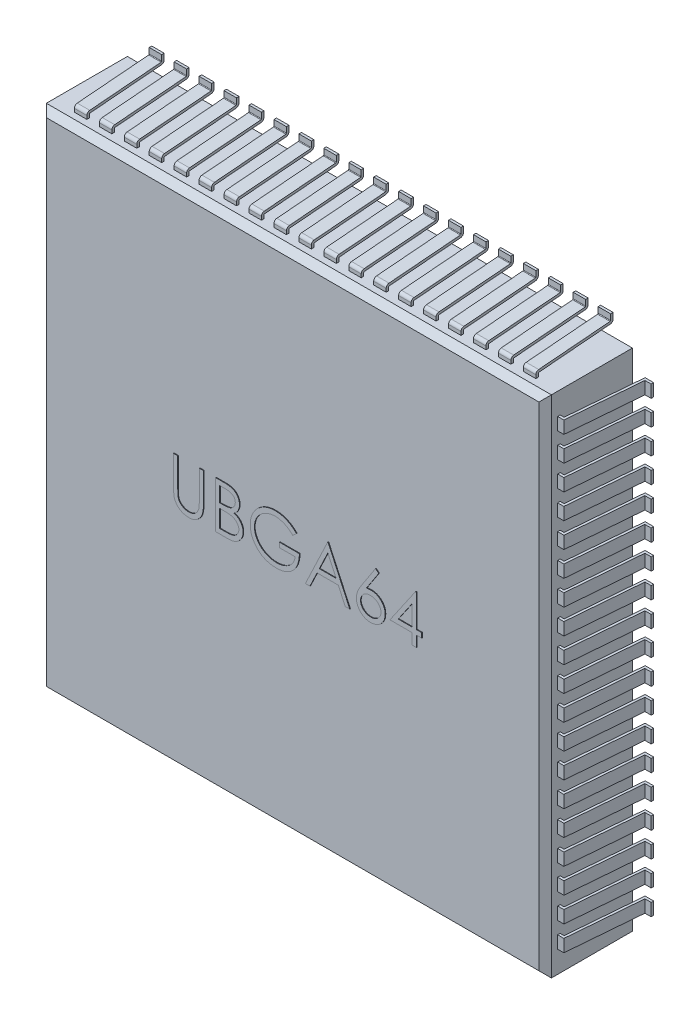
from build123d import *

# Parameters (mm, degrees)
COMPONENT_OUTLINE_W   = 8.1
COMPONENT_OUTLINE_H   = 8.1
EXTRUDE1_DEPTH        = 1.4
EXTRUDE_THIN1_DEPTH   = 0.1
LPATTERN1_COUNT       = 10
LPATTERN1_PITCH       = 0.4
LPATTERN1_COL_COUNT   = 10
LPATTERN1_COL_PITCH   = 0.4
MIRROR1_COPY_1_DEPTH  = 0.1
MIRROR1_COPY_2_DEPTH  = 0.1
MIRROR1_COPY_3_DEPTH  = 0.1
MIRROR1_COPY_4_DEPTH  = 0.1
MIRROR1_COPY_5_DEPTH  = 0.1
MIRROR1_COPY_6_DEPTH  = 0.1
MIRROR1_COPY_7_DEPTH  = 0.1
MIRROR1_COPY_8_DEPTH  = 0.1
MIRROR1_COPY_9_DEPTH  = 0.1
MIRROR1_COPY_10_DEPTH = 0.1
MIRROR1_COPY_11_DEPTH = 0.1
MIRROR1_COPY_12_DEPTH = 0.1
MIRROR1_COPY_13_DEPTH = 0.1
MIRROR1_COPY_14_DEPTH = 0.1
MIRROR1_COPY_15_DEPTH = 0.1
MIRROR1_COPY_16_DEPTH = 0.1
MIRROR1_COPY_17_DEPTH = 0.1
MIRROR1_COPY_18_DEPTH = 0.1
EXTRUDE_THIN2_DEPTH   = 0.1
LPATTERN2_COUNT       = 10
LPATTERN2_PITCH       = 0.4
LPATTERN2_COL_COUNT   = 10
LPATTERN2_COL_PITCH   = 0.4
MIRROR2_COPY_1_DEPTH  = 0.1
MIRROR2_COPY_2_DEPTH  = 0.1
MIRROR2_COPY_3_DEPTH  = 0.1
MIRROR2_COPY_4_DEPTH  = 0.1
MIRROR2_COPY_5_DEPTH  = 0.1
MIRROR2_COPY_6_DEPTH  = 0.1
MIRROR2_COPY_7_DEPTH  = 0.1
MIRROR2_COPY_8_DEPTH  = 0.1
MIRROR2_COPY_9_DEPTH  = 0.1
MIRROR2_COPY_10_DEPTH = 0.1
MIRROR2_COPY_11_DEPTH = 0.1
MIRROR2_COPY_12_DEPTH = 0.1
MIRROR2_COPY_13_DEPTH = 0.1
MIRROR2_COPY_14_DEPTH = 0.1
MIRROR2_COPY_15_DEPTH = 0.1
MIRROR2_COPY_16_DEPTH = 0.1
MIRROR2_COPY_17_DEPTH = 0.1
MIRROR2_COPY_18_DEPTH = 0.1
CHAMFER1_SIZE         = 0.1
EXTRUDE2_DEPTH        = 0.01


with BuildPart() as part:
    # COMPONENT_OUTLINE → Extrude1 (new body)
    with BuildSketch(Plane.XY):
        Rectangle(COMPONENT_OUTLINE_W, COMPONENT_OUTLINE_H)
    extrude(amount=EXTRUDE1_DEPTH)

    # Sketch1 → Extrude-Thin1 (add, symmetric)
    with BuildSketch(Plane(origin=(0, 0, 0), x_dir=(0, 0, -1), z_dir=(1, 0, 0))):
        with BuildLine():
            Line((-1.2, 4.05), (-1.2, 4.103993356))
            ThreePointArc((-1.2, 4.103993356), (-1.186794114, 4.13784883), (-1.154152274, 4.153820644))
            Line((-1.154152274, 4.153820644), (-0.009169545, 4.249235871))
            ThreePointArc((-0.009169545, 4.249235871), (-0.002641177, 4.252430234), (0, 4.259201329))
            Line((0, 4.259201329), (0, 4.35))
            Line((0, 4.35), (0.04, 4.35))
            Line((0.04, 4.35), (0.04, 4.259201329))
            ThreePointArc((0.04, 4.259201329), (0.026794114, 4.225345854), (-0.005847726, 4.209374041))
            Line((-0.005847726, 4.209374041), (-1.150830455, 4.113958814))
            ThreePointArc((-1.150830455, 4.113958814), (-1.157358823, 4.110764451), (-1.16, 4.103993356))
            Line((-1.16, 4.103993356), (-1.16, 4.05))
            Line((-1.16, 4.05), (-1.2, 4.05))
        make_face()
    extrude_thin1 = extrude(amount=EXTRUDE_THIN1_DEPTH, both=True)

    # LPattern1: Extrude-Thin1 ×10
    with Locations(*[(-i * LPATTERN1_PITCH, 0, 0) for i in range(1, LPATTERN1_COUNT)]):
        add(extrude_thin1)

    # LPattern1 col: Extrude-Thin1 ×10
    with Locations(*[(i * LPATTERN1_COL_PITCH, 0, 0) for i in range(1, LPATTERN1_COL_COUNT)]):
        add(extrude_thin1)

    # Mirror1: Extrude-Thin1 across plane
    add(extrude_thin1.mirror(Plane.ZX))

    # Mirror1 copy 1 sketch → Mirror1 copy 1 (add, symmetric)
    with BuildSketch(Plane(origin=(-0.4, 0, 0), x_dir=(0, 0, -1), z_dir=(1, 0, 0))):
        with BuildLine():
            Line((-1.2, -4.05), (-1.2, -4.103993356))
            ThreePointArc((-1.2, -4.103993356), (-1.186794114, -4.13784883), (-1.154152274, -4.153820644))
            Line((-1.154152274, -4.153820644), (-0.009169545, -4.249235871))
            ThreePointArc((-0.009169545, -4.249235871), (-0.002641177, -4.252430234), (0, -4.259201329))
            Line((0, -4.259201329), (0, -4.35))
            Line((0, -4.35), (0.04, -4.35))
            Line((0.04, -4.35), (0.04, -4.259201329))
            ThreePointArc((0.04, -4.259201329), (0.026794114, -4.225345854), (-0.005847726, -4.209374041))
            Line((-0.005847726, -4.209374041), (-1.150830455, -4.113958814))
            ThreePointArc((-1.150830455, -4.113958814), (-1.157358823, -4.110764451), (-1.16, -4.103993356))
            Line((-1.16, -4.103993356), (-1.16, -4.05))
            Line((-1.16, -4.05), (-1.2, -4.05))
        make_face()
    extrude(amount=MIRROR1_COPY_1_DEPTH, both=True)

    # Mirror1 copy 2 sketch → Mirror1 copy 2 (add, symmetric)
    with BuildSketch(Plane(origin=(-0.8, 0, 0), x_dir=(0, 0, -1), z_dir=(1, 0, 0))):
        with BuildLine():
            Line((-1.2, -4.05), (-1.2, -4.103993356))
            ThreePointArc((-1.2, -4.103993356), (-1.186794114, -4.13784883), (-1.154152274, -4.153820644))
            Line((-1.154152274, -4.153820644), (-0.009169545, -4.249235871))
            ThreePointArc((-0.009169545, -4.249235871), (-0.002641177, -4.252430234), (0, -4.259201329))
            Line((0, -4.259201329), (0, -4.35))
            Line((0, -4.35), (0.04, -4.35))
            Line((0.04, -4.35), (0.04, -4.259201329))
            ThreePointArc((0.04, -4.259201329), (0.026794114, -4.225345854), (-0.005847726, -4.209374041))
            Line((-0.005847726, -4.209374041), (-1.150830455, -4.113958814))
            ThreePointArc((-1.150830455, -4.113958814), (-1.157358823, -4.110764451), (-1.16, -4.103993356))
            Line((-1.16, -4.103993356), (-1.16, -4.05))
            Line((-1.16, -4.05), (-1.2, -4.05))
        make_face()
    extrude(amount=MIRROR1_COPY_2_DEPTH, both=True)

    # Mirror1 copy 3 sketch → Mirror1 copy 3 (add, symmetric)
    with BuildSketch(Plane(origin=(-1.2, 0, 0), x_dir=(0, 0, -1), z_dir=(1, 0, 0))):
        with BuildLine():
            Line((-1.2, -4.05), (-1.2, -4.103993356))
            ThreePointArc((-1.2, -4.103993356), (-1.186794114, -4.13784883), (-1.154152274, -4.153820644))
            Line((-1.154152274, -4.153820644), (-0.009169545, -4.249235871))
            ThreePointArc((-0.009169545, -4.249235871), (-0.002641177, -4.252430234), (0, -4.259201329))
            Line((0, -4.259201329), (0, -4.35))
            Line((0, -4.35), (0.04, -4.35))
            Line((0.04, -4.35), (0.04, -4.259201329))
            ThreePointArc((0.04, -4.259201329), (0.026794114, -4.225345854), (-0.005847726, -4.209374041))
            Line((-0.005847726, -4.209374041), (-1.150830455, -4.113958814))
            ThreePointArc((-1.150830455, -4.113958814), (-1.157358823, -4.110764451), (-1.16, -4.103993356))
            Line((-1.16, -4.103993356), (-1.16, -4.05))
            Line((-1.16, -4.05), (-1.2, -4.05))
        make_face()
    extrude(amount=MIRROR1_COPY_3_DEPTH, both=True)

    # Mirror1 copy 4 sketch → Mirror1 copy 4 (add, symmetric)
    with BuildSketch(Plane(origin=(-1.6, 0, 0), x_dir=(0, 0, -1), z_dir=(1, 0, 0))):
        with BuildLine():
            Line((-1.2, -4.05), (-1.2, -4.103993356))
            ThreePointArc((-1.2, -4.103993356), (-1.186794114, -4.13784883), (-1.154152274, -4.153820644))
            Line((-1.154152274, -4.153820644), (-0.009169545, -4.249235871))
            ThreePointArc((-0.009169545, -4.249235871), (-0.002641177, -4.252430234), (0, -4.259201329))
            Line((0, -4.259201329), (0, -4.35))
            Line((0, -4.35), (0.04, -4.35))
            Line((0.04, -4.35), (0.04, -4.259201329))
            ThreePointArc((0.04, -4.259201329), (0.026794114, -4.225345854), (-0.005847726, -4.209374041))
            Line((-0.005847726, -4.209374041), (-1.150830455, -4.113958814))
            ThreePointArc((-1.150830455, -4.113958814), (-1.157358823, -4.110764451), (-1.16, -4.103993356))
            Line((-1.16, -4.103993356), (-1.16, -4.05))
            Line((-1.16, -4.05), (-1.2, -4.05))
        make_face()
    extrude(amount=MIRROR1_COPY_4_DEPTH, both=True)

    # Mirror1 copy 5 sketch → Mirror1 copy 5 (add, symmetric)
    with BuildSketch(Plane(origin=(-2, 0, 0), x_dir=(0, 0, -1), z_dir=(1, 0, 0))):
        with BuildLine():
            Line((-1.2, -4.05), (-1.2, -4.103993356))
            ThreePointArc((-1.2, -4.103993356), (-1.186794114, -4.13784883), (-1.154152274, -4.153820644))
            Line((-1.154152274, -4.153820644), (-0.009169545, -4.249235871))
            ThreePointArc((-0.009169545, -4.249235871), (-0.002641177, -4.252430234), (0, -4.259201329))
            Line((0, -4.259201329), (0, -4.35))
            Line((0, -4.35), (0.04, -4.35))
            Line((0.04, -4.35), (0.04, -4.259201329))
            ThreePointArc((0.04, -4.259201329), (0.026794114, -4.225345854), (-0.005847726, -4.209374041))
            Line((-0.005847726, -4.209374041), (-1.150830455, -4.113958814))
            ThreePointArc((-1.150830455, -4.113958814), (-1.157358823, -4.110764451), (-1.16, -4.103993356))
            Line((-1.16, -4.103993356), (-1.16, -4.05))
            Line((-1.16, -4.05), (-1.2, -4.05))
        make_face()
    extrude(amount=MIRROR1_COPY_5_DEPTH, both=True)

    # Mirror1 copy 6 sketch → Mirror1 copy 6 (add, symmetric)
    with BuildSketch(Plane(origin=(-2.4, 0, 0), x_dir=(0, 0, -1), z_dir=(1, 0, 0))):
        with BuildLine():
            Line((-1.2, -4.05), (-1.2, -4.103993356))
            ThreePointArc((-1.2, -4.103993356), (-1.186794114, -4.13784883), (-1.154152274, -4.153820644))
            Line((-1.154152274, -4.153820644), (-0.009169545, -4.249235871))
            ThreePointArc((-0.009169545, -4.249235871), (-0.002641177, -4.252430234), (0, -4.259201329))
            Line((0, -4.259201329), (0, -4.35))
            Line((0, -4.35), (0.04, -4.35))
            Line((0.04, -4.35), (0.04, -4.259201329))
            ThreePointArc((0.04, -4.259201329), (0.026794114, -4.225345854), (-0.005847726, -4.209374041))
            Line((-0.005847726, -4.209374041), (-1.150830455, -4.113958814))
            ThreePointArc((-1.150830455, -4.113958814), (-1.157358823, -4.110764451), (-1.16, -4.103993356))
            Line((-1.16, -4.103993356), (-1.16, -4.05))
            Line((-1.16, -4.05), (-1.2, -4.05))
        make_face()
    extrude(amount=MIRROR1_COPY_6_DEPTH, both=True)

    # Mirror1 copy 7 sketch → Mirror1 copy 7 (add, symmetric)
    with BuildSketch(Plane(origin=(-2.8, 0, 0), x_dir=(0, 0, -1), z_dir=(1, 0, 0))):
        with BuildLine():
            Line((-1.2, -4.05), (-1.2, -4.103993356))
            ThreePointArc((-1.2, -4.103993356), (-1.186794114, -4.13784883), (-1.154152274, -4.153820644))
            Line((-1.154152274, -4.153820644), (-0.009169545, -4.249235871))
            ThreePointArc((-0.009169545, -4.249235871), (-0.002641177, -4.252430234), (0, -4.259201329))
            Line((0, -4.259201329), (0, -4.35))
            Line((0, -4.35), (0.04, -4.35))
            Line((0.04, -4.35), (0.04, -4.259201329))
            ThreePointArc((0.04, -4.259201329), (0.026794114, -4.225345854), (-0.005847726, -4.209374041))
            Line((-0.005847726, -4.209374041), (-1.150830455, -4.113958814))
            ThreePointArc((-1.150830455, -4.113958814), (-1.157358823, -4.110764451), (-1.16, -4.103993356))
            Line((-1.16, -4.103993356), (-1.16, -4.05))
            Line((-1.16, -4.05), (-1.2, -4.05))
        make_face()
    extrude(amount=MIRROR1_COPY_7_DEPTH, both=True)

    # Mirror1 copy 8 sketch → Mirror1 copy 8 (add, symmetric)
    with BuildSketch(Plane(origin=(-3.2, 0, 0), x_dir=(0, 0, -1), z_dir=(1, 0, 0))):
        with BuildLine():
            Line((-1.2, -4.05), (-1.2, -4.103993356))
            ThreePointArc((-1.2, -4.103993356), (-1.186794114, -4.13784883), (-1.154152274, -4.153820644))
            Line((-1.154152274, -4.153820644), (-0.009169545, -4.249235871))
            ThreePointArc((-0.009169545, -4.249235871), (-0.002641177, -4.252430234), (0, -4.259201329))
            Line((0, -4.259201329), (0, -4.35))
            Line((0, -4.35), (0.04, -4.35))
            Line((0.04, -4.35), (0.04, -4.259201329))
            ThreePointArc((0.04, -4.259201329), (0.026794114, -4.225345854), (-0.005847726, -4.209374041))
            Line((-0.005847726, -4.209374041), (-1.150830455, -4.113958814))
            ThreePointArc((-1.150830455, -4.113958814), (-1.157358823, -4.110764451), (-1.16, -4.103993356))
            Line((-1.16, -4.103993356), (-1.16, -4.05))
            Line((-1.16, -4.05), (-1.2, -4.05))
        make_face()
    extrude(amount=MIRROR1_COPY_8_DEPTH, both=True)

    # Mirror1 copy 9 sketch → Mirror1 copy 9 (add, symmetric)
    with BuildSketch(Plane(origin=(-3.6, 0, 0), x_dir=(0, 0, -1), z_dir=(1, 0, 0))):
        with BuildLine():
            Line((-1.2, -4.05), (-1.2, -4.103993356))
            ThreePointArc((-1.2, -4.103993356), (-1.186794114, -4.13784883), (-1.154152274, -4.153820644))
            Line((-1.154152274, -4.153820644), (-0.009169545, -4.249235871))
            ThreePointArc((-0.009169545, -4.249235871), (-0.002641177, -4.252430234), (0, -4.259201329))
            Line((0, -4.259201329), (0, -4.35))
            Line((0, -4.35), (0.04, -4.35))
            Line((0.04, -4.35), (0.04, -4.259201329))
            ThreePointArc((0.04, -4.259201329), (0.026794114, -4.225345854), (-0.005847726, -4.209374041))
            Line((-0.005847726, -4.209374041), (-1.150830455, -4.113958814))
            ThreePointArc((-1.150830455, -4.113958814), (-1.157358823, -4.110764451), (-1.16, -4.103993356))
            Line((-1.16, -4.103993356), (-1.16, -4.05))
            Line((-1.16, -4.05), (-1.2, -4.05))
        make_face()
    extrude(amount=MIRROR1_COPY_9_DEPTH, both=True)

    # Mirror1 copy 10 sketch → Mirror1 copy 10 (add, symmetric)
    with BuildSketch(Plane(origin=(0.4, 0, 0), x_dir=(0, 0, -1), z_dir=(1, 0, 0))):
        with BuildLine():
            Line((-1.2, -4.05), (-1.2, -4.103993356))
            ThreePointArc((-1.2, -4.103993356), (-1.186794114, -4.13784883), (-1.154152274, -4.153820644))
            Line((-1.154152274, -4.153820644), (-0.009169545, -4.249235871))
            ThreePointArc((-0.009169545, -4.249235871), (-0.002641177, -4.252430234), (0, -4.259201329))
            Line((0, -4.259201329), (0, -4.35))
            Line((0, -4.35), (0.04, -4.35))
            Line((0.04, -4.35), (0.04, -4.259201329))
            ThreePointArc((0.04, -4.259201329), (0.026794114, -4.225345854), (-0.005847726, -4.209374041))
            Line((-0.005847726, -4.209374041), (-1.150830455, -4.113958814))
            ThreePointArc((-1.150830455, -4.113958814), (-1.157358823, -4.110764451), (-1.16, -4.103993356))
            Line((-1.16, -4.103993356), (-1.16, -4.05))
            Line((-1.16, -4.05), (-1.2, -4.05))
        make_face()
    extrude(amount=MIRROR1_COPY_10_DEPTH, both=True)

    # Mirror1 copy 11 sketch → Mirror1 copy 11 (add, symmetric)
    with BuildSketch(Plane(origin=(0.8, 0, 0), x_dir=(0, 0, -1), z_dir=(1, 0, 0))):
        with BuildLine():
            Line((-1.2, -4.05), (-1.2, -4.103993356))
            ThreePointArc((-1.2, -4.103993356), (-1.186794114, -4.13784883), (-1.154152274, -4.153820644))
            Line((-1.154152274, -4.153820644), (-0.009169545, -4.249235871))
            ThreePointArc((-0.009169545, -4.249235871), (-0.002641177, -4.252430234), (0, -4.259201329))
            Line((0, -4.259201329), (0, -4.35))
            Line((0, -4.35), (0.04, -4.35))
            Line((0.04, -4.35), (0.04, -4.259201329))
            ThreePointArc((0.04, -4.259201329), (0.026794114, -4.225345854), (-0.005847726, -4.209374041))
            Line((-0.005847726, -4.209374041), (-1.150830455, -4.113958814))
            ThreePointArc((-1.150830455, -4.113958814), (-1.157358823, -4.110764451), (-1.16, -4.103993356))
            Line((-1.16, -4.103993356), (-1.16, -4.05))
            Line((-1.16, -4.05), (-1.2, -4.05))
        make_face()
    extrude(amount=MIRROR1_COPY_11_DEPTH, both=True)

    # Mirror1 copy 12 sketch → Mirror1 copy 12 (add, symmetric)
    with BuildSketch(Plane(origin=(1.2, 0, 0), x_dir=(0, 0, -1), z_dir=(1, 0, 0))):
        with BuildLine():
            Line((-1.2, -4.05), (-1.2, -4.103993356))
            ThreePointArc((-1.2, -4.103993356), (-1.186794114, -4.13784883), (-1.154152274, -4.153820644))
            Line((-1.154152274, -4.153820644), (-0.009169545, -4.249235871))
            ThreePointArc((-0.009169545, -4.249235871), (-0.002641177, -4.252430234), (0, -4.259201329))
            Line((0, -4.259201329), (0, -4.35))
            Line((0, -4.35), (0.04, -4.35))
            Line((0.04, -4.35), (0.04, -4.259201329))
            ThreePointArc((0.04, -4.259201329), (0.026794114, -4.225345854), (-0.005847726, -4.209374041))
            Line((-0.005847726, -4.209374041), (-1.150830455, -4.113958814))
            ThreePointArc((-1.150830455, -4.113958814), (-1.157358823, -4.110764451), (-1.16, -4.103993356))
            Line((-1.16, -4.103993356), (-1.16, -4.05))
            Line((-1.16, -4.05), (-1.2, -4.05))
        make_face()
    extrude(amount=MIRROR1_COPY_12_DEPTH, both=True)

    # Mirror1 copy 13 sketch → Mirror1 copy 13 (add, symmetric)
    with BuildSketch(Plane(origin=(1.6, 0, 0), x_dir=(0, 0, -1), z_dir=(1, 0, 0))):
        with BuildLine():
            Line((-1.2, -4.05), (-1.2, -4.103993356))
            ThreePointArc((-1.2, -4.103993356), (-1.186794114, -4.13784883), (-1.154152274, -4.153820644))
            Line((-1.154152274, -4.153820644), (-0.009169545, -4.249235871))
            ThreePointArc((-0.009169545, -4.249235871), (-0.002641177, -4.252430234), (0, -4.259201329))
            Line((0, -4.259201329), (0, -4.35))
            Line((0, -4.35), (0.04, -4.35))
            Line((0.04, -4.35), (0.04, -4.259201329))
            ThreePointArc((0.04, -4.259201329), (0.026794114, -4.225345854), (-0.005847726, -4.209374041))
            Line((-0.005847726, -4.209374041), (-1.150830455, -4.113958814))
            ThreePointArc((-1.150830455, -4.113958814), (-1.157358823, -4.110764451), (-1.16, -4.103993356))
            Line((-1.16, -4.103993356), (-1.16, -4.05))
            Line((-1.16, -4.05), (-1.2, -4.05))
        make_face()
    extrude(amount=MIRROR1_COPY_13_DEPTH, both=True)

    # Mirror1 copy 14 sketch → Mirror1 copy 14 (add, symmetric)
    with BuildSketch(Plane(origin=(2, 0, 0), x_dir=(0, 0, -1), z_dir=(1, 0, 0))):
        with BuildLine():
            Line((-1.2, -4.05), (-1.2, -4.103993356))
            ThreePointArc((-1.2, -4.103993356), (-1.186794114, -4.13784883), (-1.154152274, -4.153820644))
            Line((-1.154152274, -4.153820644), (-0.009169545, -4.249235871))
            ThreePointArc((-0.009169545, -4.249235871), (-0.002641177, -4.252430234), (0, -4.259201329))
            Line((0, -4.259201329), (0, -4.35))
            Line((0, -4.35), (0.04, -4.35))
            Line((0.04, -4.35), (0.04, -4.259201329))
            ThreePointArc((0.04, -4.259201329), (0.026794114, -4.225345854), (-0.005847726, -4.209374041))
            Line((-0.005847726, -4.209374041), (-1.150830455, -4.113958814))
            ThreePointArc((-1.150830455, -4.113958814), (-1.157358823, -4.110764451), (-1.16, -4.103993356))
            Line((-1.16, -4.103993356), (-1.16, -4.05))
            Line((-1.16, -4.05), (-1.2, -4.05))
        make_face()
    extrude(amount=MIRROR1_COPY_14_DEPTH, both=True)

    # Mirror1 copy 15 sketch → Mirror1 copy 15 (add, symmetric)
    with BuildSketch(Plane(origin=(2.4, 0, 0), x_dir=(0, 0, -1), z_dir=(1, 0, 0))):
        with BuildLine():
            Line((-1.2, -4.05), (-1.2, -4.103993356))
            ThreePointArc((-1.2, -4.103993356), (-1.186794114, -4.13784883), (-1.154152274, -4.153820644))
            Line((-1.154152274, -4.153820644), (-0.009169545, -4.249235871))
            ThreePointArc((-0.009169545, -4.249235871), (-0.002641177, -4.252430234), (0, -4.259201329))
            Line((0, -4.259201329), (0, -4.35))
            Line((0, -4.35), (0.04, -4.35))
            Line((0.04, -4.35), (0.04, -4.259201329))
            ThreePointArc((0.04, -4.259201329), (0.026794114, -4.225345854), (-0.005847726, -4.209374041))
            Line((-0.005847726, -4.209374041), (-1.150830455, -4.113958814))
            ThreePointArc((-1.150830455, -4.113958814), (-1.157358823, -4.110764451), (-1.16, -4.103993356))
            Line((-1.16, -4.103993356), (-1.16, -4.05))
            Line((-1.16, -4.05), (-1.2, -4.05))
        make_face()
    extrude(amount=MIRROR1_COPY_15_DEPTH, both=True)

    # Mirror1 copy 16 sketch → Mirror1 copy 16 (add, symmetric)
    with BuildSketch(Plane(origin=(2.8, 0, 0), x_dir=(0, 0, -1), z_dir=(1, 0, 0))):
        with BuildLine():
            Line((-1.2, -4.05), (-1.2, -4.103993356))
            ThreePointArc((-1.2, -4.103993356), (-1.186794114, -4.13784883), (-1.154152274, -4.153820644))
            Line((-1.154152274, -4.153820644), (-0.009169545, -4.249235871))
            ThreePointArc((-0.009169545, -4.249235871), (-0.002641177, -4.252430234), (0, -4.259201329))
            Line((0, -4.259201329), (0, -4.35))
            Line((0, -4.35), (0.04, -4.35))
            Line((0.04, -4.35), (0.04, -4.259201329))
            ThreePointArc((0.04, -4.259201329), (0.026794114, -4.225345854), (-0.005847726, -4.209374041))
            Line((-0.005847726, -4.209374041), (-1.150830455, -4.113958814))
            ThreePointArc((-1.150830455, -4.113958814), (-1.157358823, -4.110764451), (-1.16, -4.103993356))
            Line((-1.16, -4.103993356), (-1.16, -4.05))
            Line((-1.16, -4.05), (-1.2, -4.05))
        make_face()
    extrude(amount=MIRROR1_COPY_16_DEPTH, both=True)

    # Mirror1 copy 17 sketch → Mirror1 copy 17 (add, symmetric)
    with BuildSketch(Plane(origin=(3.2, 0, 0), x_dir=(0, 0, -1), z_dir=(1, 0, 0))):
        with BuildLine():
            Line((-1.2, -4.05), (-1.2, -4.103993356))
            ThreePointArc((-1.2, -4.103993356), (-1.186794114, -4.13784883), (-1.154152274, -4.153820644))
            Line((-1.154152274, -4.153820644), (-0.009169545, -4.249235871))
            ThreePointArc((-0.009169545, -4.249235871), (-0.002641177, -4.252430234), (0, -4.259201329))
            Line((0, -4.259201329), (0, -4.35))
            Line((0, -4.35), (0.04, -4.35))
            Line((0.04, -4.35), (0.04, -4.259201329))
            ThreePointArc((0.04, -4.259201329), (0.026794114, -4.225345854), (-0.005847726, -4.209374041))
            Line((-0.005847726, -4.209374041), (-1.150830455, -4.113958814))
            ThreePointArc((-1.150830455, -4.113958814), (-1.157358823, -4.110764451), (-1.16, -4.103993356))
            Line((-1.16, -4.103993356), (-1.16, -4.05))
            Line((-1.16, -4.05), (-1.2, -4.05))
        make_face()
    extrude(amount=MIRROR1_COPY_17_DEPTH, both=True)

    # Mirror1 copy 18 sketch → Mirror1 copy 18 (add, symmetric)
    with BuildSketch(Plane(origin=(3.6, 0, 0), x_dir=(0, 0, -1), z_dir=(1, 0, 0))):
        with BuildLine():
            Line((-1.2, -4.05), (-1.2, -4.103993356))
            ThreePointArc((-1.2, -4.103993356), (-1.186794114, -4.13784883), (-1.154152274, -4.153820644))
            Line((-1.154152274, -4.153820644), (-0.009169545, -4.249235871))
            ThreePointArc((-0.009169545, -4.249235871), (-0.002641177, -4.252430234), (0, -4.259201329))
            Line((0, -4.259201329), (0, -4.35))
            Line((0, -4.35), (0.04, -4.35))
            Line((0.04, -4.35), (0.04, -4.259201329))
            ThreePointArc((0.04, -4.259201329), (0.026794114, -4.225345854), (-0.005847726, -4.209374041))
            Line((-0.005847726, -4.209374041), (-1.150830455, -4.113958814))
            ThreePointArc((-1.150830455, -4.113958814), (-1.157358823, -4.110764451), (-1.16, -4.103993356))
            Line((-1.16, -4.103993356), (-1.16, -4.05))
            Line((-1.16, -4.05), (-1.2, -4.05))
        make_face()
    extrude(amount=MIRROR1_COPY_18_DEPTH, both=True)

    # Sketch2 → Extrude-Thin2 (add, symmetric)
    with BuildSketch(Plane(origin=(0, 0, 0), x_dir=(1, 0, 0), z_dir=(0, 1, 0))):
        Polygon((4.05, -1.2), (4.15, -1.2), (4.25, 0), (4.35, 0), (4.35, 0.04), (4.213194685, 0.04), (4.113194685, -1.16), (4.05, -1.16), align=None)
    extrude_thin2 = extrude(amount=EXTRUDE_THIN2_DEPTH, both=True)

    # LPattern2: Extrude-Thin2 ×10
    with Locations(*[(0, i * LPATTERN2_PITCH, 0) for i in range(1, LPATTERN2_COUNT)]):
        add(extrude_thin2)

    # LPattern2 col: Extrude-Thin2 ×10
    with Locations(*[(0, -i * LPATTERN2_COL_PITCH, 0) for i in range(1, LPATTERN2_COL_COUNT)]):
        add(extrude_thin2)

    # Mirror2: Extrude-Thin2 across plane
    add(extrude_thin2.mirror(Plane(origin=(0, 0, 0), x_dir=(0, 0, 1), z_dir=(1, 0, 0))))

    # Mirror2 copy 1 sketch → Mirror2 copy 1 (add, symmetric)
    with BuildSketch(Plane(origin=(0, 0.4, 0), x_dir=(-1, 0, 0), z_dir=(0, 1, 0))):
        Polygon((4.05, 1.2), (4.15, 1.2), (4.25, 0), (4.35, 0), (4.35, -0.04), (4.213194685, -0.04), (4.113194685, 1.16), (4.05, 1.16), align=None)
    extrude(amount=MIRROR2_COPY_1_DEPTH, both=True)

    # Mirror2 copy 2 sketch → Mirror2 copy 2 (add, symmetric)
    with BuildSketch(Plane(origin=(0, 0.8, 0), x_dir=(-1, 0, 0), z_dir=(0, 1, 0))):
        Polygon((4.05, 1.2), (4.15, 1.2), (4.25, 0), (4.35, 0), (4.35, -0.04), (4.213194685, -0.04), (4.113194685, 1.16), (4.05, 1.16), align=None)
    extrude(amount=MIRROR2_COPY_2_DEPTH, both=True)

    # Mirror2 copy 3 sketch → Mirror2 copy 3 (add, symmetric)
    with BuildSketch(Plane(origin=(0, 1.2, 0), x_dir=(-1, 0, 0), z_dir=(0, 1, 0))):
        Polygon((4.05, 1.2), (4.15, 1.2), (4.25, 0), (4.35, 0), (4.35, -0.04), (4.213194685, -0.04), (4.113194685, 1.16), (4.05, 1.16), align=None)
    extrude(amount=MIRROR2_COPY_3_DEPTH, both=True)

    # Mirror2 copy 4 sketch → Mirror2 copy 4 (add, symmetric)
    with BuildSketch(Plane(origin=(0, 1.6, 0), x_dir=(-1, 0, 0), z_dir=(0, 1, 0))):
        Polygon((4.05, 1.2), (4.15, 1.2), (4.25, 0), (4.35, 0), (4.35, -0.04), (4.213194685, -0.04), (4.113194685, 1.16), (4.05, 1.16), align=None)
    extrude(amount=MIRROR2_COPY_4_DEPTH, both=True)

    # Mirror2 copy 5 sketch → Mirror2 copy 5 (add, symmetric)
    with BuildSketch(Plane(origin=(0, 2, 0), x_dir=(-1, 0, 0), z_dir=(0, 1, 0))):
        Polygon((4.05, 1.2), (4.15, 1.2), (4.25, 0), (4.35, 0), (4.35, -0.04), (4.213194685, -0.04), (4.113194685, 1.16), (4.05, 1.16), align=None)
    extrude(amount=MIRROR2_COPY_5_DEPTH, both=True)

    # Mirror2 copy 6 sketch → Mirror2 copy 6 (add, symmetric)
    with BuildSketch(Plane(origin=(0, 2.4, 0), x_dir=(-1, 0, 0), z_dir=(0, 1, 0))):
        Polygon((4.05, 1.2), (4.15, 1.2), (4.25, 0), (4.35, 0), (4.35, -0.04), (4.213194685, -0.04), (4.113194685, 1.16), (4.05, 1.16), align=None)
    extrude(amount=MIRROR2_COPY_6_DEPTH, both=True)

    # Mirror2 copy 7 sketch → Mirror2 copy 7 (add, symmetric)
    with BuildSketch(Plane(origin=(0, 2.8, 0), x_dir=(-1, 0, 0), z_dir=(0, 1, 0))):
        Polygon((4.05, 1.2), (4.15, 1.2), (4.25, 0), (4.35, 0), (4.35, -0.04), (4.213194685, -0.04), (4.113194685, 1.16), (4.05, 1.16), align=None)
    extrude(amount=MIRROR2_COPY_7_DEPTH, both=True)

    # Mirror2 copy 8 sketch → Mirror2 copy 8 (add, symmetric)
    with BuildSketch(Plane(origin=(0, 3.2, 0), x_dir=(-1, 0, 0), z_dir=(0, 1, 0))):
        Polygon((4.05, 1.2), (4.15, 1.2), (4.25, 0), (4.35, 0), (4.35, -0.04), (4.213194685, -0.04), (4.113194685, 1.16), (4.05, 1.16), align=None)
    extrude(amount=MIRROR2_COPY_8_DEPTH, both=True)

    # Mirror2 copy 9 sketch → Mirror2 copy 9 (add, symmetric)
    with BuildSketch(Plane(origin=(0, 3.6, 0), x_dir=(-1, 0, 0), z_dir=(0, 1, 0))):
        Polygon((4.05, 1.2), (4.15, 1.2), (4.25, 0), (4.35, 0), (4.35, -0.04), (4.213194685, -0.04), (4.113194685, 1.16), (4.05, 1.16), align=None)
    extrude(amount=MIRROR2_COPY_9_DEPTH, both=True)

    # Mirror2 copy 10 sketch → Mirror2 copy 10 (add, symmetric)
    with BuildSketch(Plane(origin=(0, -0.4, 0), x_dir=(-1, 0, 0), z_dir=(0, 1, 0))):
        Polygon((4.05, 1.2), (4.15, 1.2), (4.25, 0), (4.35, 0), (4.35, -0.04), (4.213194685, -0.04), (4.113194685, 1.16), (4.05, 1.16), align=None)
    extrude(amount=MIRROR2_COPY_10_DEPTH, both=True)

    # Mirror2 copy 11 sketch → Mirror2 copy 11 (add, symmetric)
    with BuildSketch(Plane(origin=(0, -0.8, 0), x_dir=(-1, 0, 0), z_dir=(0, 1, 0))):
        Polygon((4.05, 1.2), (4.15, 1.2), (4.25, 0), (4.35, 0), (4.35, -0.04), (4.213194685, -0.04), (4.113194685, 1.16), (4.05, 1.16), align=None)
    extrude(amount=MIRROR2_COPY_11_DEPTH, both=True)

    # Mirror2 copy 12 sketch → Mirror2 copy 12 (add, symmetric)
    with BuildSketch(Plane(origin=(0, -1.2, 0), x_dir=(-1, 0, 0), z_dir=(0, 1, 0))):
        Polygon((4.05, 1.2), (4.15, 1.2), (4.25, 0), (4.35, 0), (4.35, -0.04), (4.213194685, -0.04), (4.113194685, 1.16), (4.05, 1.16), align=None)
    extrude(amount=MIRROR2_COPY_12_DEPTH, both=True)

    # Mirror2 copy 13 sketch → Mirror2 copy 13 (add, symmetric)
    with BuildSketch(Plane(origin=(0, -1.6, 0), x_dir=(-1, 0, 0), z_dir=(0, 1, 0))):
        Polygon((4.05, 1.2), (4.15, 1.2), (4.25, 0), (4.35, 0), (4.35, -0.04), (4.213194685, -0.04), (4.113194685, 1.16), (4.05, 1.16), align=None)
    extrude(amount=MIRROR2_COPY_13_DEPTH, both=True)

    # Mirror2 copy 14 sketch → Mirror2 copy 14 (add, symmetric)
    with BuildSketch(Plane(origin=(0, -2, 0), x_dir=(-1, 0, 0), z_dir=(0, 1, 0))):
        Polygon((4.05, 1.2), (4.15, 1.2), (4.25, 0), (4.35, 0), (4.35, -0.04), (4.213194685, -0.04), (4.113194685, 1.16), (4.05, 1.16), align=None)
    extrude(amount=MIRROR2_COPY_14_DEPTH, both=True)

    # Mirror2 copy 15 sketch → Mirror2 copy 15 (add, symmetric)
    with BuildSketch(Plane(origin=(0, -2.4, 0), x_dir=(-1, 0, 0), z_dir=(0, 1, 0))):
        Polygon((4.05, 1.2), (4.15, 1.2), (4.25, 0), (4.35, 0), (4.35, -0.04), (4.213194685, -0.04), (4.113194685, 1.16), (4.05, 1.16), align=None)
    extrude(amount=MIRROR2_COPY_15_DEPTH, both=True)

    # Mirror2 copy 16 sketch → Mirror2 copy 16 (add, symmetric)
    with BuildSketch(Plane(origin=(0, -2.8, 0), x_dir=(-1, 0, 0), z_dir=(0, 1, 0))):
        Polygon((4.05, 1.2), (4.15, 1.2), (4.25, 0), (4.35, 0), (4.35, -0.04), (4.213194685, -0.04), (4.113194685, 1.16), (4.05, 1.16), align=None)
    extrude(amount=MIRROR2_COPY_16_DEPTH, both=True)

    # Mirror2 copy 17 sketch → Mirror2 copy 17 (add, symmetric)
    with BuildSketch(Plane(origin=(0, -3.2, 0), x_dir=(-1, 0, 0), z_dir=(0, 1, 0))):
        Polygon((4.05, 1.2), (4.15, 1.2), (4.25, 0), (4.35, 0), (4.35, -0.04), (4.213194685, -0.04), (4.113194685, 1.16), (4.05, 1.16), align=None)
    extrude(amount=MIRROR2_COPY_17_DEPTH, both=True)

    # Mirror2 copy 18 sketch → Mirror2 copy 18 (add, symmetric)
    with BuildSketch(Plane(origin=(0, -3.6, 0), x_dir=(-1, 0, 0), z_dir=(0, 1, 0))):
        Polygon((4.05, 1.2), (4.15, 1.2), (4.25, 0), (4.35, 0), (4.35, -0.04), (4.213194685, -0.04), (4.113194685, 1.16), (4.05, 1.16), align=None)
    extrude(amount=MIRROR2_COPY_18_DEPTH, both=True)

    # Chamfer1
    chamfer1_edges = [part.edges().sort_by_distance(p)[0] for p in [
        (0, -4.05, 1.4),
        (4.05, 0, 1.4),
        (0, 4.05, 1.4),
        (-4.05, 0, 1.4),
    ]]
    chamfer(chamfer1_edges, length=CHAMFER1_SIZE)

    # Sketch3 → Extrude2 (add)
    with BuildSketch(Plane.XY.offset(1.4)):
        with BuildLine():
            Line((-1.900467401, 0.317104243), (-1.833159709, 0.317104243))
            Line((-1.833159709, 0.317104243), (-1.833159709, -0.132264748))
            add(Edge.make_bspline(
                [(-1.833159709, -0.132264748), (-1.833169725, -0.138624905), (-1.833188734, -0.1506944), (-1.833061766, -0.167873322), (-1.832706187, -0.183145992), (-1.83248201, -0.196571281), (-1.831983296, -0.208087584), (-1.831576572, -0.217757293), (-1.831053595, -0.225534622), (-1.83042507, -0.230073392), (-1.830154901, -0.232024363)],
                knots=[0, 0, 0, 0, 1.528628734, 2.90083645, 4.128790002, 5.200304208, 6.127813768, 6.898992206, 7.526736466, 8, 8, 8, 8], degree=3))
            add(Edge.make_bspline(
                [(-1.830154901, -0.232024363), (-1.829045446, -0.239062955), (-1.826889049, -0.25274354), (-1.821393396, -0.272223886), (-1.813718218, -0.289780627), (-1.80462328, -0.305961618), (-1.79263772, -0.320316481), (-1.77827982, -0.333540406), (-1.760884584, -0.345105793), (-1.741543025, -0.355680967), (-1.720696189, -0.364180628), (-1.699393774, -0.370607777), (-1.677955993, -0.374524684), (-1.663603958, -0.374978228), (-1.656477017, -0.375203449)],
                knots=[0, 0, 0, 0, 1.035780045, 2.013197591, 2.933192213, 3.817615948, 4.702609284, 5.640816605, 6.646850145, 7.73207398, 8.84249596, 9.914020372, 10.964143139, 12, 12, 12, 12], degree=3))
            add(Edge.make_bspline(
                [(-1.656477017, -0.375203449), (-1.650358358, -0.374973339), (-1.63815638, -0.374514446), (-1.620026431, -0.371672711), (-1.602369265, -0.366551161), (-1.585097691, -0.359942642), (-1.568908194, -0.351211015), (-1.553791742, -0.341124406), (-1.54029947, -0.329293504), (-1.527987042, -0.316200573), (-1.51726527, -0.301427759), (-1.507971454, -0.28529673), (-1.500358755, -0.267564727), (-1.496599428, -0.255103065), (-1.494668122, -0.248701046)],
                knots=[0, 0, 0, 0, 0.994687771, 1.983630487, 2.973142513, 3.978332533, 4.983357753, 5.956394766, 6.925816176, 7.893390482, 8.871859704, 9.88551698, 10.913711441, 12, 12, 12, 12], degree=3))
            add(Edge.make_bspline(
                [(-1.494668122, -0.248701046), (-1.494025238, -0.246054923), (-1.492592634, -0.240158294), (-1.491253981, -0.230189446), (-1.489859726, -0.218427439), (-1.488892318, -0.204787765), (-1.487949199, -0.189316128), (-1.487384969, -0.17193193), (-1.487124177, -0.152698296), (-1.487046459, -0.139276047), (-1.487005863, -0.132264748)],
                knots=[0, 0, 0, 0, 0.558680831, 1.244966039, 2.062412453, 2.990489873, 4.051219941, 5.244515665, 6.560634259, 8, 8, 8, 8], degree=3))
            Line((-1.487005863, -0.132264748), (-1.487005863, 0.317104243))
            Line((-1.487005863, 0.317104243), (-1.41969817, 0.317104243))
            Line((-1.41969817, 0.317104243), (-1.41969817, -0.135870517))
            add(Edge.make_bspline(
                [(-1.41969817, -0.135870517), (-1.419752625, -0.144034455), (-1.419858896, -0.159966877), (-1.420780448, -0.183313597), (-1.422249805, -0.205460664), (-1.424325824, -0.226411057), (-1.42707661, -0.246089805), (-1.430135586, -0.264669398), (-1.4340312, -0.282016468), (-1.438581215, -0.298266272), (-1.443782689, -0.313734596), (-1.450520078, -0.328415013), (-1.458111043, -0.342753813), (-1.467114183, -0.356534122), (-1.477230907, -0.369816955), (-1.488684839, -0.382521757), (-1.501097159, -0.394851553), (-1.514674208, -0.406490067), (-1.529192177, -0.417163355), (-1.544607883, -0.426548591), (-1.560802905, -0.434482224), (-1.577735146, -0.441012779), (-1.595411832, -0.44592305), (-1.613833409, -0.449582012), (-1.633041808, -0.451661076), (-1.646105663, -0.451970061), (-1.652721007, -0.452126526)],
                knots=[0, 0, 0, 0, 1.316592851, 2.569410997, 3.76748051, 4.895814652, 5.963796859, 6.97159953, 7.931736103, 8.829262218, 9.692595152, 10.560224239, 11.431080259, 12.30701507, 13.211635791, 14.121146779, 15.063487852, 16.031507147, 17.00238618, 17.966455255, 18.938106653, 19.907068911, 20.888905087, 21.893141452, 22.933117798, 24, 24, 24, 24], degree=3))
            add(Edge.make_bspline(
                [(-1.652721007, -0.452126526), (-1.659935815, -0.451958362), (-1.674091242, -0.451628425), (-1.694949399, -0.449737836), (-1.714945298, -0.446176751), (-1.734290129, -0.441642478), (-1.752720521, -0.43538882), (-1.770483402, -0.428082079), (-1.787274548, -0.41910838), (-1.803366361, -0.409124082), (-1.818328809, -0.397890231), (-1.832063967, -0.385645908), (-1.844594511, -0.372587255), (-1.855709231, -0.358572891), (-1.865592278, -0.343711811), (-1.874105895, -0.327961974), (-1.881415876, -0.311329478), (-1.885188712, -0.299768078), (-1.887096007, -0.293923401)],
                knots=[0, 0, 0, 0, 1.13879206, 2.234305948, 3.301075583, 4.341971843, 5.366689343, 6.369221514, 7.369726634, 8.367512178, 9.355451585, 10.318319045, 11.268648973, 12.207971039, 13.137398894, 14.081662264, 15.030215811, 16, 16, 16, 16], degree=3))
            add(Edge.make_bspline(
                [(-1.887096007, -0.293923401), (-1.888205398, -0.289930707), (-1.890611692, -0.281270464), (-1.893188541, -0.266937645), (-1.895354773, -0.250434448), (-1.897391678, -0.231759744), (-1.898593598, -0.210899058), (-1.899647335, -0.187861433), (-1.900474825, -0.162619013), (-1.900469945, -0.145035903), (-1.900467401, -0.135870517)],
                knots=[0, 0, 0, 0, 0.625038921, 1.35572334, 2.194682327, 3.136881307, 4.189498639, 5.346923369, 6.617055217, 8, 8, 8, 8], degree=3))
            Line((-1.900467401, -0.135870517), (-1.900467401, 0.317104243))
        make_face()
        with BuildLine():
            Line((-1.227390478, 0.317104243), (-1.081056344, 0.317104243))
            add(Edge.make_bspline(
                [(-1.081056344, 0.317104243), (-1.073893098, 0.317066582), (-1.060008946, 0.316993586), (-1.039819066, 0.315861486), (-1.020908606, 0.314317843), (-1.003272084, 0.311868537), (-0.986917647, 0.308913157), (-0.971796011, 0.305334196), (-0.95795526, 0.301042779), (-0.941431102, 0.294218576), (-0.92259096, 0.284077897), (-0.902191305, 0.269093204), (-0.884747539, 0.250764819), (-0.869707614, 0.230089964), (-0.857750231, 0.207346585), (-0.849099667, 0.183076759), (-0.84362298, 0.157593528), (-0.843059744, 0.140098562), (-0.842775094, 0.131256887)],
                knots=[0, 0, 0, 0, 1.001505555, 1.941167018, 2.826882275, 3.653841531, 4.429895133, 5.150066043, 5.825578002, 6.45369114, 7.647487171, 8.808567382, 9.977351308, 11.170798116, 12.373658725, 13.556498008, 14.765093433, 16, 16, 16, 16], degree=3))
            add(Edge.make_bspline(
                [(-0.842775094, 0.131256887), (-0.843009355, 0.122974197), (-0.8434697, 0.106697929), (-0.84787172, 0.082892048), (-0.854763291, 0.060231073), (-0.864342988, 0.038797704), (-0.876793415, 0.019076216), (-0.891548769, 0.000907516), (-0.909350941, -0.014939139), (-0.922688779, -0.023798333), (-0.929463795, -0.028298401)],
                knots=[0, 0, 0, 0, 1.044552857, 2.05264487, 3.044412934, 4.028983338, 5.005914585, 5.980388656, 6.974128949, 8, 8, 8, 8], degree=3))
            add(Edge.make_bspline(
                [(-0.929463795, -0.028298401), (-0.920943704, -0.031569473), (-0.904642658, -0.037827842), (-0.882209941, -0.048892584), (-0.862882474, -0.060927322), (-0.846511657, -0.074069862), (-0.832510731, -0.088236035), (-0.820285101, -0.10363356), (-0.809853378, -0.120463294), (-0.800914894, -0.138549766), (-0.793940161, -0.157708295), (-0.788716753, -0.177759175), (-0.785723728, -0.198630508), (-0.785297805, -0.212834518), (-0.785082786, -0.220005132)],
                knots=[0, 0, 0, 0, 1.27268992, 2.434971085, 3.483601985, 4.442670788, 5.356604649, 6.2567628, 7.179492994, 8.113709626, 9.066344395, 10.018646069, 10.999752585, 12, 12, 12, 12], degree=3))
            add(Edge.make_bspline(
                [(-0.785082786, -0.220005132), (-0.78529211, -0.227326605), (-0.785703961, -0.241731807), (-0.788742526, -0.262893622), (-0.793887335, -0.283116825), (-0.800974009, -0.302532221), (-0.810223077, -0.32110225), (-0.821479069, -0.338847949), (-0.834900118, -0.35559102), (-0.84991359, -0.371517511), (-0.866898336, -0.385837751), (-0.88522314, -0.398591117), (-0.90511878, -0.409079558), (-0.926258493, -0.417890134), (-0.948879418, -0.424620248), (-0.972879977, -0.429328657), (-0.99823947, -0.432501165), (-1.01564156, -0.432761995), (-1.024565959, -0.432895757)],
                knots=[0, 0, 0, 0, 0.978564426, 1.925352924, 2.850884081, 3.763762016, 4.682927383, 5.618979971, 6.567305752, 7.547517671, 8.540179244, 9.531824382, 10.526200242, 11.540722885, 12.589160233, 13.674978461, 14.80764778, 16, 16, 16, 16], degree=3))
            Line((-1.024565959, -0.432895757), (-1.227390478, -0.432895757))
            Line((-1.227390478, -0.432895757), (-1.227390478, 0.317104243))
        make_face()
        with BuildLine():
            Line((-1.160082786, 0.240181166), (-1.160082786, -0.000203449))
            Line((-1.160082786, -0.000203449), (-1.11486043, -0.000203449))
            add(Edge.make_bspline(
                [(-1.11486043, -0.000203449), (-1.108249974, -0.000117752), (-1.095477226, 4.7834e-05), (-1.076980105, 0.000522159), (-1.059810458, 0.001850311), (-1.043997922, 0.003178082), (-1.029567399, 0.005336922), (-1.016550857, 0.007906662), (-1.004744015, 0.010624428), (-0.991128398, 0.015246461), (-0.975684195, 0.022077391), (-0.959219958, 0.032678499), (-0.944705429, 0.045305146), (-0.932448889, 0.059874638), (-0.922417859, 0.075917392), (-0.915450634, 0.093177438), (-0.910726216, 0.111224609), (-0.91029946, 0.123614234), (-0.910082786, 0.129904724)],
                knots=[0, 0, 0, 0, 1.156816544, 2.235205308, 3.236616184, 4.169592532, 5.011045266, 5.787822928, 6.49130361, 7.128639758, 8.301311294, 9.436451833, 10.541879658, 11.654887649, 12.756523258, 13.837046038, 14.901820046, 16, 16, 16, 16], degree=3))
            add(Edge.make_bspline(
                [(-0.910082786, 0.129904724), (-0.910195539, 0.134067389), (-0.910416716, 0.142232912), (-0.912228138, 0.154136345), (-0.915306904, 0.165331434), (-0.919261395, 0.175971601), (-0.924787543, 0.18572414), (-0.931293999, 0.194926254), (-0.939155219, 0.203264565), (-0.948103214, 0.211058029), (-0.958390776, 0.21796757), (-0.970011767, 0.224019162), (-0.983123412, 0.228892186), (-0.997504738, 0.233159933), (-1.013377114, 0.236157424), (-1.030557376, 0.238654579), (-1.049186244, 0.239925881), (-1.06207448, 0.240094173), (-1.068736632, 0.240181166)],
                knots=[0, 0, 0, 0, 0.91205012, 1.789085906, 2.630437955, 3.453916878, 4.269457761, 5.079663411, 5.91843418, 6.774407191, 7.675494373, 8.627863946, 9.638891023, 10.736472738, 11.911756761, 13.175263542, 14.539845004, 16, 16, 16, 16], degree=3))
            Line((-1.068736632, 0.240181166), (-1.160082786, 0.240181166))
        make_face(mode=Mode.SUBTRACT)
        with BuildLine():
            Line((-1.160082786, -0.077126526), (-1.160082786, -0.35597268))
            Line((-1.160082786, -0.35597268), (-1.06422942, -0.35597268))
            add(Edge.make_bspline(
                [(-1.06422942, -0.35597268), (-1.057368222, -0.355890449), (-1.044144167, -0.355731958), (-1.025051046, -0.355214554), (-1.007354667, -0.354037637), (-0.99113578, -0.352184955), (-0.976219255, -0.350175288), (-0.962784033, -0.34747287), (-0.950721205, -0.344376664), (-0.936733854, -0.33959077), (-0.920983102, -0.332155812), (-0.904009347, -0.320945621), (-0.888918015, -0.307590626), (-0.876102602, -0.292134002), (-0.865599819, -0.275327289), (-0.857959364, -0.257510428), (-0.853247038, -0.238977815), (-0.852676573, -0.226342091), (-0.852390478, -0.220005132)],
                knots=[0, 0, 0, 0, 1.160039823, 2.235823828, 3.228722157, 4.157150951, 4.99529583, 5.772374946, 6.472645482, 7.099169577, 8.269452708, 9.405989375, 10.527446681, 11.663510218, 12.788923519, 13.866172445, 14.929861265, 16, 16, 16, 16], degree=3))
            add(Edge.make_bspline(
                [(-0.852390478, -0.220005132), (-0.852449643, -0.216042273), (-0.852567019, -0.208180477), (-0.854337151, -0.196627088), (-0.856911552, -0.185435829), (-0.860239716, -0.174576313), (-0.865086745, -0.164244875), (-0.87074529, -0.154237184), (-0.877379876, -0.14454001), (-0.887717912, -0.132280241), (-0.902754766, -0.118155167), (-0.924120503, -0.104325702), (-0.948414567, -0.093172601), (-0.966034744, -0.088436999), (-0.975136872, -0.085990709)],
                knots=[0, 0, 0, 0, 0.723448775, 1.435228256, 2.130040452, 2.821711965, 3.505591119, 4.210454504, 4.921174351, 5.648778258, 7.137944449, 8.670945889, 10.280296675, 12, 12, 12, 12], degree=3))
            add(Edge.make_bspline(
                [(-0.975136872, -0.085990709), (-0.978785964, -0.085250334), (-0.986697948, -0.083645048), (-0.999599573, -0.08195054), (-1.014328688, -0.080440884), (-1.030919304, -0.079324208), (-1.049392413, -0.078169948), (-1.069787467, -0.077721058), (-1.092021177, -0.077185502), (-1.107448114, -0.077146688), (-1.115461392, -0.077126526)],
                knots=[0, 0, 0, 0, 0.634451884, 1.375622551, 2.216452059, 3.157844607, 4.20941857, 5.370758133, 6.634282058, 8, 8, 8, 8], degree=3))
            Line((-1.115461392, -0.077126526), (-1.160082786, -0.077126526))
        make_face(mode=Mode.SUBTRACT)
        with BuildLine():
            Line((0.070686445, 0.189099435), (0.012994137, 0.134411935))
            add(Edge.make_bspline(
                [(0.012994137, 0.134411935), (0.002554376, 0.144232834), (-0.018076206, 0.163640448), (-0.051710544, 0.188821375), (-0.086802751, 0.210392683), (-0.123169715, 0.227944019), (-0.159910833, 0.241948182), (-0.196538428, 0.251918498), (-0.232676793, 0.258276899), (-0.256712625, 0.259037263), (-0.268556344, 0.259411935)],
                knots=[0, 0, 0, 0, 1.08915593, 2.152340314, 3.188132944, 4.216796309, 5.218260357, 6.173443236, 7.099959455, 8, 8, 8, 8], degree=3))
            add(Edge.make_bspline(
                [(-0.268556344, 0.259411935), (-0.275823779, 0.259323305), (-0.290339802, 0.259146275), (-0.311901647, 0.256886801), (-0.333237355, 0.253637187), (-0.35430665, 0.248935356), (-0.375150497, 0.242976272), (-0.395696402, 0.235522244), (-0.415982693, 0.226831835), (-0.435818282, 0.216789876), (-0.455048389, 0.20575848), (-0.473210569, 0.193533793), (-0.490420583, 0.180507624), (-0.506354959, 0.166353842), (-0.521105357, 0.151200657), (-0.535022865, 0.135329949), (-0.547618, 0.118308116), (-0.558994678, 0.100448339), (-0.569143596, 0.082064298), (-0.578102593, 0.063332944), (-0.585623398, 0.044316403), (-0.591573995, 0.024990815), (-0.596483421, 0.005505689), (-0.599937194, -0.014273894), (-0.601884349, -0.034369112), (-0.602221159, -0.047825668), (-0.602390478, -0.054590469)],
                knots=[0, 0, 0, 0, 1.02818874, 2.053710826, 3.065248034, 4.081641283, 5.106893873, 6.131558223, 7.173050175, 8.228653731, 9.27666206, 10.308777013, 11.325269123, 12.329503258, 13.32196095, 14.316845687, 15.314881793, 16.315733098, 17.311955233, 18.285320748, 19.252783886, 20.203351036, 21.145449891, 22.095197417, 23.042428769, 24, 24, 24, 24], degree=3))
            add(Edge.make_bspline(
                [(-0.602390478, -0.054590469), (-0.602228539, -0.061505644), (-0.601905101, -0.075317111), (-0.599835033, -0.095930127), (-0.595993267, -0.116236999), (-0.59085733, -0.136304456), (-0.584432869, -0.156166866), (-0.576424441, -0.175738118), (-0.566938955, -0.195017488), (-0.555959694, -0.213831263), (-0.543919793, -0.232157625), (-0.53043199, -0.249420379), (-0.516104722, -0.265849403), (-0.500416029, -0.281079924), (-0.483868984, -0.29551933), (-0.465969211, -0.308769799), (-0.447068684, -0.321086561), (-0.427138567, -0.332314387), (-0.406395113, -0.342344787), (-0.385125809, -0.351264194), (-0.363262706, -0.358609766), (-0.340920701, -0.364596503), (-0.318126428, -0.369503709), (-0.294764185, -0.372660669), (-0.271005748, -0.374951562), (-0.254990326, -0.375119062), (-0.246921728, -0.375203449)],
                knots=[0, 0, 0, 0, 0.93586088, 1.869166235, 2.799637598, 3.729985548, 4.670839027, 5.622275134, 6.589130586, 7.576015415, 8.568469353, 9.55398029, 10.53834874, 11.515998671, 12.510579167, 13.508179873, 14.527009472, 15.561807829, 16.601455013, 17.643573243, 18.680854198, 19.719860599, 20.772568776, 21.833555941, 22.908541556, 24, 24, 24, 24], degree=3))
            add(Edge.make_bspline(
                [(-0.246921728, -0.375203449), (-0.237197797, -0.375000183), (-0.218103277, -0.374601037), (-0.190034754, -0.371493832), (-0.163076953, -0.366640947), (-0.137305624, -0.35953397), (-0.112690833, -0.350468896), (-0.089142346, -0.339541314), (-0.066845562, -0.326332087), (-0.045733453, -0.311423401), (-0.026285485, -0.29481308), (-0.008745316, -0.276889268), (0.006607289, -0.257738968), (0.020001153, -0.237474972), (0.031081579, -0.215929549), (0.040176464, -0.193208286), (0.047147884, -0.169300962), (0.050009664, -0.152781326), (0.051455676, -0.144434219)],
                knots=[0, 0, 0, 0, 1.13008108, 2.219097802, 3.278683437, 4.311054135, 5.322181354, 6.324827112, 7.324222904, 8.330512327, 9.32562643, 10.293043162, 11.24128371, 12.174520618, 13.111833804, 14.052305215, 15.015860969, 16, 16, 16, 16], degree=3))
            Line((0.051455676, -0.144434219), (-0.198544324, -0.144434219))
            Line((-0.198544324, -0.144434219), (-0.198544324, -0.067511142))
            Line((-0.198544324, -0.067511142), (0.118763368, -0.067511142))
            add(Edge.make_bspline(
                [(0.118763368, -0.067511142), (0.118397829, -0.081848461), (0.117682403, -0.109909184), (0.112664064, -0.150831385), (0.104560526, -0.189482462), (0.093490459, -0.22590312), (0.079160042, -0.260041747), (0.061723072, -0.291933004), (0.040900474, -0.321370865), (0.017433951, -0.348595651), (-0.008901754, -0.372880482), (-0.03739503, -0.394224612), (-0.068092952, -0.412203744), (-0.100966482, -0.426831028), (-0.135908003, -0.438246884), (-0.17299837, -0.446340794), (-0.212187285, -0.451190072), (-0.239045144, -0.451809653), (-0.252781103, -0.452126526)],
                knots=[0, 0, 0, 0, 1.140356446, 2.231883559, 3.274166699, 4.278491846, 5.25512956, 6.21435461, 7.1637429, 8.11826594, 9.068280886, 10.0076534, 10.945064095, 11.891975133, 12.864533718, 13.863980011, 14.907571808, 16, 16, 16, 16], degree=3))
            add(Edge.make_bspline(
                [(-0.252781103, -0.452126526), (-0.261247561, -0.452004572), (-0.277946144, -0.451764038), (-0.302608485, -0.450054607), (-0.326590833, -0.447423055), (-0.349889692, -0.443449099), (-0.372590765, -0.438581674), (-0.394580676, -0.432348805), (-0.415943192, -0.425134084), (-0.436711332, -0.416927868), (-0.456696592, -0.407419656), (-0.475987989, -0.396853305), (-0.494692158, -0.385283299), (-0.512681694, -0.372509546), (-0.530050327, -0.358627591), (-0.546686065, -0.343609608), (-0.562682039, -0.327501511), (-0.572702138, -0.316063152), (-0.577751055, -0.310299603)],
                knots=[0, 0, 0, 0, 1.107784379, 2.184907829, 3.233506516, 4.263428166, 5.276301166, 6.270063455, 7.25232949, 8.225834625, 9.190232166, 10.146266622, 11.1027726, 12.066435141, 13.031522626, 14.010570082, 14.99756817, 16, 16, 16, 16], degree=3))
            add(Edge.make_bspline(
                [(-0.577751055, -0.310299603), (-0.585076612, -0.301155892), (-0.599606129, -0.283020245), (-0.618308591, -0.253963114), (-0.634251749, -0.223877002), (-0.647187711, -0.192678153), (-0.657288729, -0.16039575), (-0.664532926, -0.127071045), (-0.668777345, -0.092661124), (-0.669388818, -0.06937571), (-0.66969817, -0.057595276)],
                knots=[0, 0, 0, 0, 1.023165419, 2.029347347, 3.013907458, 3.994755782, 4.975994455, 5.96558838, 6.970761222, 8, 8, 8, 8], degree=3))
            add(Edge.make_bspline(
                [(-0.66969817, -0.057595276), (-0.669584119, -0.048773937), (-0.669357467, -0.031243371), (-0.666609142, -0.005216805), (-0.662665981, 0.020347629), (-0.656870184, 0.045429034), (-0.649563841, 0.070044161), (-0.640445237, 0.094204439), (-0.629828474, 0.117924126), (-0.617488724, 0.141039955), (-0.60375634, 0.163245186), (-0.588852722, 0.184450429), (-0.572566236, 0.204269515), (-0.55516285, 0.222953439), (-0.536434924, 0.240267478), (-0.516557904, 0.25637193), (-0.495516474, 0.271288399), (-0.473244435, 0.284781935), (-0.450074217, 0.296902711), (-0.42606136, 0.30752897), (-0.401213193, 0.316311109), (-0.375715876, 0.323762633), (-0.349376412, 0.329273021), (-0.32238594, 0.33326918), (-0.294603773, 0.336003595), (-0.275824624, 0.336223507), (-0.266302738, 0.336335012)],
                knots=[0, 0, 0, 0, 1.008945113, 2.00506715, 2.99143336, 3.967273523, 4.948097931, 5.927297278, 6.919902385, 7.919676788, 8.923139349, 9.905703106, 10.883022732, 11.856032218, 12.825136022, 13.798837087, 14.781400844, 15.773989409, 16.776158564, 17.77167057, 18.775803737, 19.789618931, 20.80898985, 21.851988756, 22.910860228, 24, 24, 24, 24], degree=3))
            add(Edge.make_bspline(
                [(-0.266302738, 0.336335012), (-0.2585374, 0.336210835), (-0.243139647, 0.335964607), (-0.22022699, 0.334257897), (-0.197668487, 0.33155278), (-0.175430689, 0.327861325), (-0.153589325, 0.322833392), (-0.132082174, 0.316816616), (-0.110878059, 0.309811226), (-0.090043434, 0.301456473), (-0.069438209, 0.291973553), (-0.048947815, 0.281299249), (-0.028642262, 0.269251033), (-0.008486338, 0.255793133), (0.01164706, 0.241156686), (0.031439484, 0.224923081), (0.051368686, 0.207732491), (0.064183361, 0.195372023), (0.070686445, 0.189099435)],
                knots=[0, 0, 0, 0, 0.985871117, 1.954866573, 2.915460327, 3.869826059, 4.81536089, 5.759505086, 6.70452669, 7.649098992, 8.607881297, 9.583363685, 10.581137262, 11.603961102, 12.659522466, 13.73993555, 14.853081303, 16, 16, 16, 16], degree=3))
        make_face()
        Polygon((0.58030183, 0.317104243), (0.926455676, -0.432895757), (0.853288608, -0.432895757), (0.742411205, -0.192511142), (0.402417214, -0.192511142), (0.288384762, -0.432895757), (0.214917214, -0.432895757), (0.570686445, 0.317104243), align=None)
        Polygon((0.574742935, 0.170920349), (0.438925628, -0.115588065), (0.706954474, -0.115588065), align=None, mode=Mode.SUBTRACT)
        with BuildLine():
            Line((1.339917214, 0.336335012), (1.391750147, 0.295619868))
            Line((1.391750147, 0.295619868), (1.19358308, -0.007414988))
            add(Edge.make_bspline(
                [(1.19358308, -0.007414988), (1.20677671, -0.005312018), (1.232512379, -0.001209937), (1.258562214, -0.000533234), (1.271257358, -0.000203449)],
                knots=[0, 0, 0, 0, 1.025318673, 2, 2, 2, 2], degree=3))
            add(Edge.make_bspline(
                [(1.271257358, -0.000203449), (1.278880036, -0.000408331), (1.293885051, -0.000811633), (1.31591508, -0.003915315), (1.337084137, -0.008806411), (1.357304483, -0.01593618), (1.376648693, -0.025043827), (1.395227778, -0.035959299), (1.412692495, -0.049246231), (1.429267747, -0.064088721), (1.444316411, -0.080528075), (1.457639851, -0.097971219), (1.468831307, -0.116399979), (1.477911433, -0.135805022), (1.484962478, -0.156156434), (1.490102688, -0.177428179), (1.493141172, -0.199634922), (1.493553777, -0.214737389), (1.493763368, -0.222408978)],
                knots=[0, 0, 0, 0, 1.04369286, 2.054478336, 3.041073146, 4.015093852, 4.984733326, 5.965804835, 6.960378782, 7.985147595, 9.009457201, 10.008161701, 10.986880575, 11.956520048, 12.937015923, 13.931873656, 14.949455224, 16, 16, 16, 16], degree=3))
            add(Edge.make_bspline(
                [(1.493763368, -0.222408978), (1.493458417, -0.232904629), (1.492858345, -0.253557586), (1.486878961, -0.283638309), (1.477587608, -0.312295277), (1.464306709, -0.339070956), (1.447810484, -0.36392865), (1.427693857, -0.385954107), (1.404670253, -0.405597686), (1.378637367, -0.422024104), (1.350621018, -0.435439044), (1.321188447, -0.445074453), (1.290625487, -0.451006625), (1.269881642, -0.451750325), (1.259388368, -0.452126526)],
                knots=[0, 0, 0, 0, 1.031375318, 2.029502543, 3.004789286, 3.987476834, 4.960371455, 5.9300674, 6.912260825, 7.929083631, 8.949397511, 9.960523116, 10.96833055, 12, 12, 12, 12], degree=3))
            add(Edge.make_bspline(
                [(1.259388368, -0.452126526), (1.249296218, -0.451799054), (1.229305435, -0.451150388), (1.199898408, -0.445371972), (1.171642047, -0.436006165), (1.144734323, -0.423103105), (1.119808477, -0.406804987), (1.097508698, -0.387184499), (1.077946175, -0.364661042), (1.061665899, -0.339238111), (1.048753313, -0.311918834), (1.039069758, -0.2834323), (1.03341342, -0.253882304), (1.032623015, -0.233850632), (1.032224906, -0.223761142)],
                knots=[0, 0, 0, 0, 1.012016664, 2.004627821, 2.994792927, 3.992885782, 4.990978636, 5.973936114, 6.964471063, 7.975201453, 8.993600317, 9.990122807, 10.98767138, 12, 12, 12, 12], degree=3))
            add(Edge.make_bspline(
                [(1.032224906, -0.223761142), (1.032478073, -0.216037303), (1.032994991, -0.200266699), (1.036604289, -0.17638155), (1.042403888, -0.151942032), (1.048898941, -0.131208991), (1.055761572, -0.114224379), (1.06147283, -0.100530774), (1.068581544, -0.086439115), (1.076161554, -0.071466193), (1.084895169, -0.055997886), (1.094391379, -0.039775671), (1.104912733, -0.023057544), (1.112288482, -0.011712359), (1.116059041, -0.005912584)],
                knots=[0, 0, 0, 0, 1.173818275, 2.396712641, 3.66331629, 4.989737886, 5.693666774, 6.447286557, 7.243889047, 8.091586357, 8.998013824, 9.943181721, 10.948533338, 12, 12, 12, 12], degree=3))
            Line((1.116059041, -0.005912584), (1.339917214, 0.336335012))
        make_face()
        with BuildLine():
            add(Edge.make_bspline(
                [(1.257134762, -0.077126526), (1.251421424, -0.07729325), (1.240261615, -0.07761891), (1.223888597, -0.079510035), (1.208392901, -0.083071264), (1.193569229, -0.087606906), (1.179694721, -0.093843276), (1.166668542, -0.101418662), (1.154440316, -0.110337485), (1.143138126, -0.120473395), (1.132891056, -0.131570831), (1.124066528, -0.143457157), (1.116454585, -0.155845915), (1.110265624, -0.168840616), (1.105446322, -0.182436295), (1.101960268, -0.19657042), (1.100020178, -0.211337771), (1.099697414, -0.221351879), (1.099532599, -0.226465469)],
                knots=[0, 0, 0, 0, 1.129588631, 2.206414736, 3.251139165, 4.268635594, 5.265702196, 6.250456724, 7.242448911, 8.251968645, 9.246821453, 10.222880186, 11.173611482, 12.116736599, 13.062300278, 14.020270554, 14.989073742, 16, 16, 16, 16], degree=3))
            add(Edge.make_bspline(
                [(1.099532599, -0.226465469), (1.099666819, -0.231533322), (1.099930005, -0.241470626), (1.102319788, -0.256114736), (1.105970163, -0.270207217), (1.111400248, -0.283675417), (1.117877438, -0.296724628), (1.126428579, -0.308882189), (1.135903604, -0.320886489), (1.147229447, -0.331815376), (1.159384454, -0.341984653), (1.172370426, -0.350873279), (1.185904703, -0.358477459), (1.200170007, -0.364436979), (1.214963947, -0.369327898), (1.23040978, -0.372769644), (1.246518249, -0.374715471), (1.257430093, -0.375038655), (1.262994137, -0.375203449)],
                knots=[0, 0, 0, 0, 0.989467248, 1.94019797, 2.891935182, 3.827694429, 4.772920941, 5.730924762, 6.725747692, 7.756678648, 8.79901574, 9.819492441, 10.826891316, 11.826466727, 12.835195252, 13.867842842, 14.912794438, 16, 16, 16, 16], degree=3))
            add(Edge.make_bspline(
                [(1.262994137, -0.375203449), (1.268558173, -0.375038642), (1.279469999, -0.374715432), (1.295578597, -0.372769789), (1.311023951, -0.369327364), (1.325819632, -0.364438914), (1.34007851, -0.358470283), (1.35360095, -0.350920586), (1.366464113, -0.341929989), (1.378627099, -0.331832755), (1.3899058, -0.320824286), (1.399608074, -0.308989346), (1.407897338, -0.296626368), (1.414633235, -0.283726821), (1.420003512, -0.270199073), (1.423672398, -0.256116918), (1.426057245, -0.241470055), (1.42632111, -0.231533129), (1.426455676, -0.226465469)],
                knots=[0, 0, 0, 0, 1.087397944, 2.132534446, 3.165364764, 4.174271784, 5.174024072, 6.181601208, 7.194203697, 8.236725232, 9.267838612, 10.269026844, 11.221737037, 12.171628256, 13.107553087, 14.05945871, 15.010357665, 16, 16, 16, 16], degree=3))
            add(Edge.make_bspline(
                [(1.426455676, -0.226465469), (1.426337756, -0.221345208), (1.426106317, -0.211295801), (1.423488614, -0.196577025), (1.419858105, -0.182364481), (1.414376027, -0.168747492), (1.407253911, -0.155779794), (1.398578895, -0.143395879), (1.388543344, -0.131500805), (1.376951014, -0.120451631), (1.364331678, -0.110348686), (1.350914053, -0.10143021), (1.33687663, -0.093903429), (1.322233642, -0.087623336), (1.30681731, -0.083091306), (1.290876523, -0.079522753), (1.2742074, -0.07762375), (1.262898127, -0.077294379), (1.257134762, -0.077126526)],
                knots=[0, 0, 0, 0, 0.978206639, 1.919901502, 2.851605144, 3.780102724, 4.718870031, 5.675451981, 6.667674623, 7.690630536, 8.733308323, 9.756129687, 10.767539656, 11.776269907, 12.797430371, 13.836405707, 14.897401972, 16, 16, 16, 16], degree=3))
        make_face(mode=Mode.SUBTRACT)
        Polygon((1.980091493, 0.336335012), (1.993763368, 0.336335012), (1.993763368, -0.182895757), (2.08030183, -0.182895757), (2.08030183, -0.259818834), (1.993763368, -0.259818834), (1.993763368, -0.432895757), (1.926455676, -0.432895757), (1.926455676, -0.259818834), (1.570686445, -0.259818834), align=None)
        Polygon((1.926455676, -0.182895757), (1.926455676, 0.142825397), (1.702897983, -0.182895757), align=None, mode=Mode.SUBTRACT)
    extrude(amount=EXTRUDE2_DEPTH)


solid = part.part
